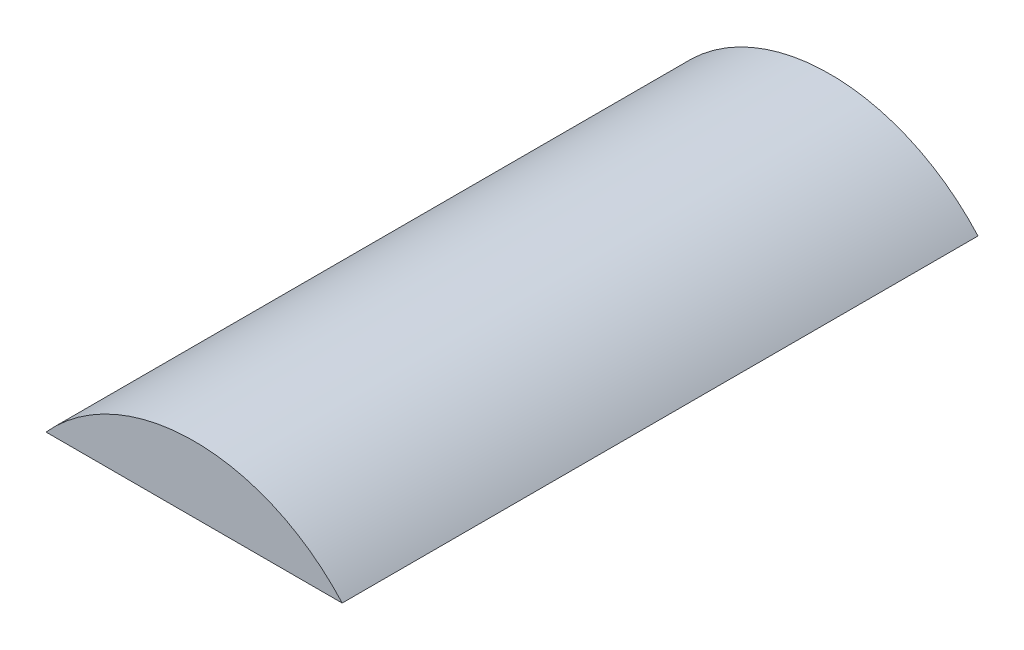
from build123d import *

# Parameters (mm, degrees)
BOSS_EXTRUDE1_DEPTH = 4.8


with BuildPart() as part:
    # Sketch1 → Boss-Extrude1 (new body)
    with BuildSketch(Plane.XY):
        with BuildLine():
            Line((-1.118033989, 1), (1.118033989, 1))
            ThreePointArc((1.118033989, 1), (0, 1.5), (-1.118033989, 1))
        make_face()
    extrude(amount=-BOSS_EXTRUDE1_DEPTH)


solid = part.part
